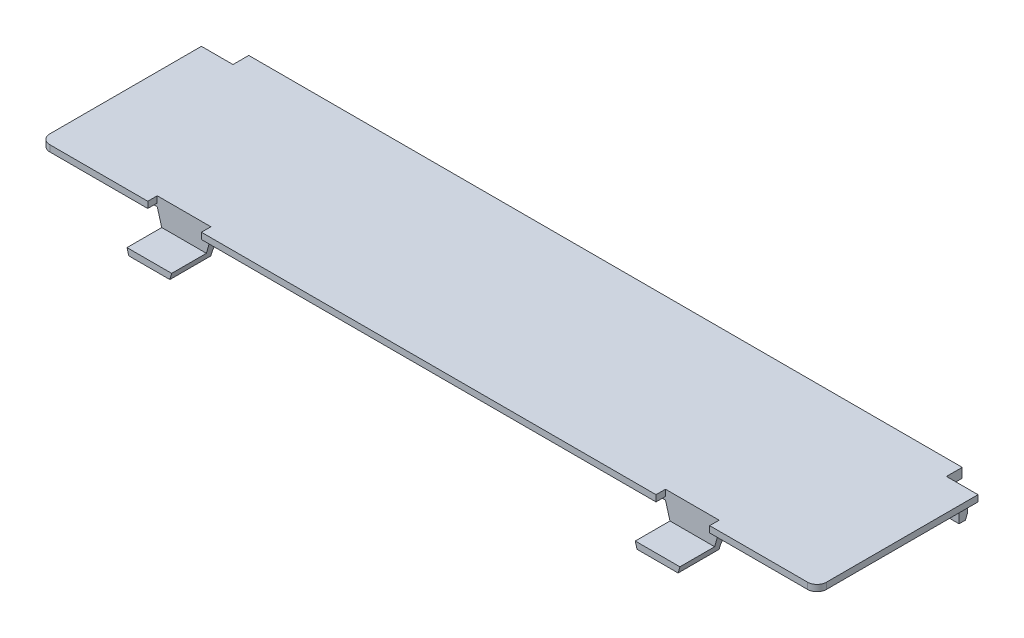
from build123d import *

# Parameters (mm, degrees)
BOSS_EXTRUDE1_DEPTH = 1.5
CUT_EXTRUDE4_DEPTH  = 0.5
SKETCH3_W           = 8.5
SKETCH3_H           = 6.5
BOSS_EXTRUDE2_DEPTH = 5
SKETCH4_W           = 8.5
SKETCH4_H           = 5.5
CUT_EXTRUDE1_DEPTH  = 4
CUT_EXTRUDE2_DEPTH  = 33
FILLET1_R           = 3
SKETCH6_W           = 5
SKETCH6_H           = 2.5
CUT_EXTRUDE3_DEPTH  = 1.5
BOSS_EXTRUDE4_DEPTH = 3
SKETCH10_R          = 1
BOSS_EXTRUDE5_DEPTH = 2.5
FILLET2_R           = 1


with BuildPart() as part:
    # Sketch2 → Boss-Extrude1 (new body)
    with BuildSketch(Plane(origin=(0, 0, 0), x_dir=(1, 0, 0), z_dir=(0, 1, 0))):
        with BuildLine():
            Line((-61.5, 13.25), (61.5, 13.25))
            Line((61.5, 13.25), (61.5, -13.25))
            ThreePointArc((61.5, -13.25), (61.060660172, -14.310660172), (60, -14.75))
            Line((60, -14.75), (-60, -14.75))
            ThreePointArc((-60, -14.75), (-61.060660172, -14.310660172), (-61.5, -13.25))
            Line((-61.5, -13.25), (-61.5, 13.25))
        make_face()
    extrude(amount=BOSS_EXTRUDE1_DEPTH)

    # Sketch9 → Cut-Extrude4 (cut)
    with BuildSketch(Plane.XZ):
        with BuildLine():
            Line((60, -13.25), (65, -13.25))
            Line((65, -13.25), (65, 18.25))
            Line((65, 18.25), (-65, 18.25))
            Line((-65, 18.25), (-65, -13.25))
            Line((-65, -13.25), (-60, -13.25))
            Line((-60, -13.25), (-60, 12.45))
            ThreePointArc((-60, 12.45), (-59.765685425, 13.015685425), (-59.2, 13.25))
            Line((-59.2, 13.25), (59.2, 13.25))
            ThreePointArc((59.2, 13.25), (59.765685425, 13.015685425), (60, 12.45))
            Line((60, 12.45), (60, -13.25))
        make_face()
    extrude(amount=-CUT_EXTRUDE4_DEPTH, mode=Mode.SUBTRACT)

    # Sketch3 → Boss-Extrude2 (add)
    with BuildSketch(Plane(origin=(0, 1.5, 0), x_dir=(1, 0, 0), z_dir=(0, 1, 0))):
        with Locations((-40.25, -15.5)):
            Rectangle(SKETCH3_W, SKETCH3_H)
    boss_extrude2 = extrude(amount=-BOSS_EXTRUDE2_DEPTH)

    # Sketch4 → Cut-Extrude1 (cut)
    with BuildSketch(Plane(origin=(0, 1.5, 0), x_dir=(1, 0, 0), z_dir=(0, 1, 0))):
        with Locations((-40.25, -16)):
            Rectangle(SKETCH4_W, SKETCH4_H)
    cut_extrude1 = extrude(amount=-CUT_EXTRUDE1_DEPTH, mode=Mode.SUBTRACT)

    # Sketch5 → Cut-Extrude2 (cut, through all)
    with BuildSketch(Plane.XY.offset(18.75)):
        Polygon((-44.5, 0), (-43.5, -3.5), (-44.5, -3.5), align=None)
        Polygon((-36, 0), (-36, -3.5), (-37, -3.5), align=None)
    cut_extrude2 = extrude(amount=-CUT_EXTRUDE2_DEPTH, mode=Mode.SUBTRACT)

    # Mirror1: Boss-Extrude2, Cut-Extrude1, Cut-Extrude2 across plane
    add(boss_extrude2.mirror(Plane(origin=(0, 0, 0), x_dir=(0, 0, 1), z_dir=(1, 0, 0))))
    add(cut_extrude1.mirror(Plane(origin=(0, 0, 0), x_dir=(0, 0, 1), z_dir=(1, 0, 0))), mode=Mode.SUBTRACT)
    add(cut_extrude2.mirror(Plane(origin=(0, 0, 0), x_dir=(0, 0, 1), z_dir=(1, 0, 0))), mode=Mode.SUBTRACT)

    # Fillet1
    fillet1_edges = [part.edges().sort_by_distance(p)[0] for p in [
        (40.25, 0, 12.25),
        (-40.25, 0, 12.25),
    ]]
    fillet(fillet1_edges, radius=FILLET1_R)

    # Sketch6 → Cut-Extrude3 (cut)
    with BuildSketch(Plane(origin=(0, 1.5, 0), x_dir=(1, 0, 0), z_dir=(0, 1, 0))):
        with Locations((-59, 12)):
            Rectangle(SKETCH6_W, SKETCH6_H)
    cut_extrude3 = extrude(amount=-CUT_EXTRUDE3_DEPTH, mode=Mode.SUBTRACT)

    # Sketch7 → Boss-Extrude4 (add)
    with BuildSketch(Plane.ZY.offset(56.5)):
        with BuildLine():
            Line((-10.75, 0), (-10.75, -0.5))
            ThreePointArc((-10.75, -0.5), (-11.068858925, -1.37188366), (-11.047594135, -2.3))
            Line((-11.047594135, -2.3), (-10.75, -3))
            Line((-10.75, -3), (-9.75, -3))
            Line((-9.75, -3), (-9.75, 0))
            Line((-9.75, 0), (-10.75, 0))
        make_face()
    boss_extrude4 = extrude(amount=BOSS_EXTRUDE4_DEPTH)

    # Mirror2: Cut-Extrude3, Boss-Extrude4 across plane
    add(cut_extrude3.mirror(Plane(origin=(0, 0, 0), x_dir=(0, 0, 1), z_dir=(1, 0, 0))), mode=Mode.SUBTRACT)
    add(boss_extrude4.mirror(Plane(origin=(0, 0, 0), x_dir=(0, 0, 1), z_dir=(1, 0, 0))))

    # Sketch10 → Boss-Extrude5 (add)
    with BuildSketch(Plane(origin=(0, 0, 0), x_dir=(-1, 0, 0), z_dir=(0, -1, 0))):
        with Locations((-15, 11.5)):
            Circle(SKETCH10_R)
        with Locations((15, 11.5)):
            Circle(SKETCH10_R)
    extrude(amount=BOSS_EXTRUDE5_DEPTH)

    # Fillet2
    fillet2_edges = [part.edges().sort_by_distance(p)[0] for p in [
        (-58, 0, -9.75),
        (58, 0, -9.75),
    ]]
    fillet(fillet2_edges, radius=FILLET2_R)


solid = part.part
